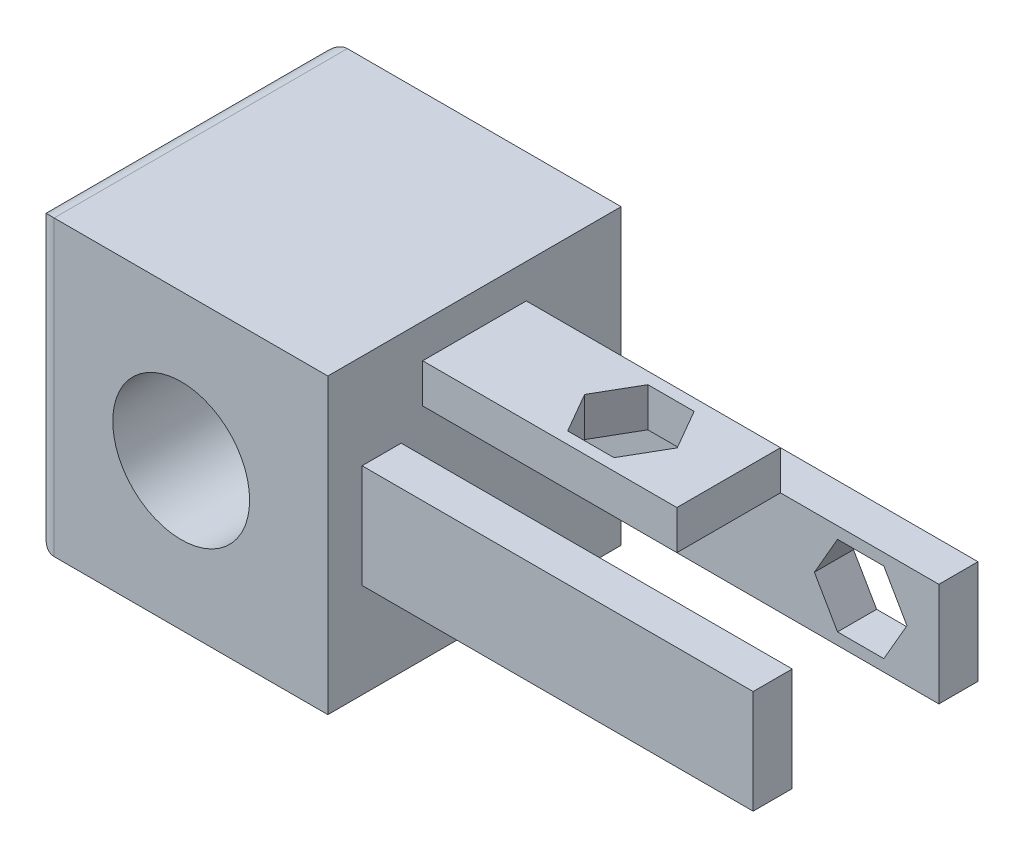
from build123d import *

# Parameters (mm, degrees)
ESBO_O1_W                  = 15
ESBO_O1_H                  = 15
ESBO_O1_R                  = 3.5
RESSALTO_EXTRUS_O1_DEPTH   = 7.5
RESSALTO_EXTRUS_O2_START   = -7.5
ESBO_O1_3_R                = 3.5
ESBO_O1_3_R_2              = 1.75
RESSALTO_EXTRUS_O2_DEPTH   = 3
ESBO_O2_3_R                = 3.5
ESBO_O2_3_R_2              = 1.6
RESSALTO_EXTRUS_O3_DEPTH   = 3
ESBO_O4_3_R                = 3.5
ESBO_O4_3_R_2              = 1.6
RESSALTO_EXTRUS_O4_DEPTH   = 3
ESBO_O6_W                  = 5.3
ESBO_O6_H                  = 2
ESBO_O6_W_2                = 2
ESBO_O6_H_2                = 5.3
RESSALTO_EXTRUS_O5_DEPTH   = 20
ESBO_O7_W                  = 7
ESBO_O7_H                  = 5.3
CORTE_EXTRUS_O3_DEPTH      = 1
CORTE_EXTRUS_O3_DEPTH_BACK = 16
CORTE_EXTRUS_O4_DEPTH      = 3
FILETE1_R                  = 1


with BuildPart() as part:
    # Esboço1 → Ressalto-extrusão1 (new body, symmetric)
    with BuildSketch(Plane.XY):
        Rectangle(ESBO_O1_W, ESBO_O1_H)
        Circle(ESBO_O1_R, mode=Mode.SUBTRACT)
    extrude(amount=RESSALTO_EXTRUS_O1_DEPTH, both=True)

    # Esboço1<3> → Ressalto-extrusão2 (add)
    with BuildSketch(Plane.XY.offset(RESSALTO_EXTRUS_O2_START)):
        Circle(ESBO_O1_3_R)
        Circle(ESBO_O1_3_R_2, mode=Mode.SUBTRACT)
    extrude(amount=RESSALTO_EXTRUS_O2_DEPTH)

    # Esboço2<3> → Ressalto-extrusão3 (add)
    with BuildSketch(Plane(origin=(7.5, 0, 0), x_dir=(0, 0, -1), z_dir=(1, 0, 0))):
        Circle(ESBO_O2_3_R)
        Circle(ESBO_O2_3_R_2, mode=Mode.SUBTRACT)
    extrude(amount=-RESSALTO_EXTRUS_O3_DEPTH)

    # Esboço4<3> → Ressalto-extrusão4 (add)
    with BuildSketch(Plane(origin=(0, 7.5, 0), x_dir=(1, 0, 0), z_dir=(0, 1, 0))):
        Circle(ESBO_O4_3_R)
        Circle(ESBO_O4_3_R_2, mode=Mode.SUBTRACT)
    extrude(amount=-RESSALTO_EXTRUS_O4_DEPTH)

    # Esboço6 → Ressalto-extrusão5 (add)
    with BuildSketch(Plane(origin=(7.5, 0, 0), x_dir=(0, 0, -1), z_dir=(1, 0, 0))):
        with Locations((0, 4.75)):
            Rectangle(ESBO_O6_W, ESBO_O6_H)
        with Locations((4.75, 0)):
            Rectangle(ESBO_O6_W_2, ESBO_O6_H_2)
        with Locations((0, -4.75)):
            Rectangle(ESBO_O6_W, ESBO_O6_H)
        with Locations((-4.75, 0)):
            Rectangle(ESBO_O6_W_2, ESBO_O6_H_2)
    extrude(amount=RESSALTO_EXTRUS_O5_DEPTH)

    # Esboço7 → Corte-extrusão3 (cut, two sides)
    with BuildSketch(Plane.XZ.offset(7.5)) as corte_extrus_o3_sk:
        with Locations((24, 0)):
            Rectangle(ESBO_O7_W, ESBO_O7_H)
        Polygon((17.867136104, 0), (16.683568052, 2.05), (14.316431948, 2.05), (13.132863896, 0), (14.316431948, -2.05), (16.683568052, -2.05), align=None)
    extrude(amount=CORTE_EXTRUS_O3_DEPTH, mode=Mode.SUBTRACT)
    extrude(corte_extrus_o3_sk.sketch, amount=-CORTE_EXTRUS_O3_DEPTH_BACK, mode=Mode.SUBTRACT)

    # Esboço8 → Corte-extrusão4 (cut)
    with BuildSketch(Plane(origin=(0, 0, -5.75), x_dir=(-1, 0, 0), z_dir=(0, 0, -1))):
        Polygon((-25.867136104, 0), (-24.683568052, -2.05), (-22.316431948, -2.05), (-21.132863896, 0), (-22.316431948, 2.05), (-24.683568052, 2.05), align=None)
    extrude(amount=-CORTE_EXTRUS_O4_DEPTH, mode=Mode.SUBTRACT)

    # Filete1
    filete1_edges = [part.edges().sort_by_distance(p)[0] for p in [
        (-7.5, -7.5, 0),
        (-7.5, 7.5, 0),
        (-7.5, 0, 7.5),
        (-7.5, 0, -7.5),
    ]]
    fillet(filete1_edges, radius=FILETE1_R)


solid = part.part
